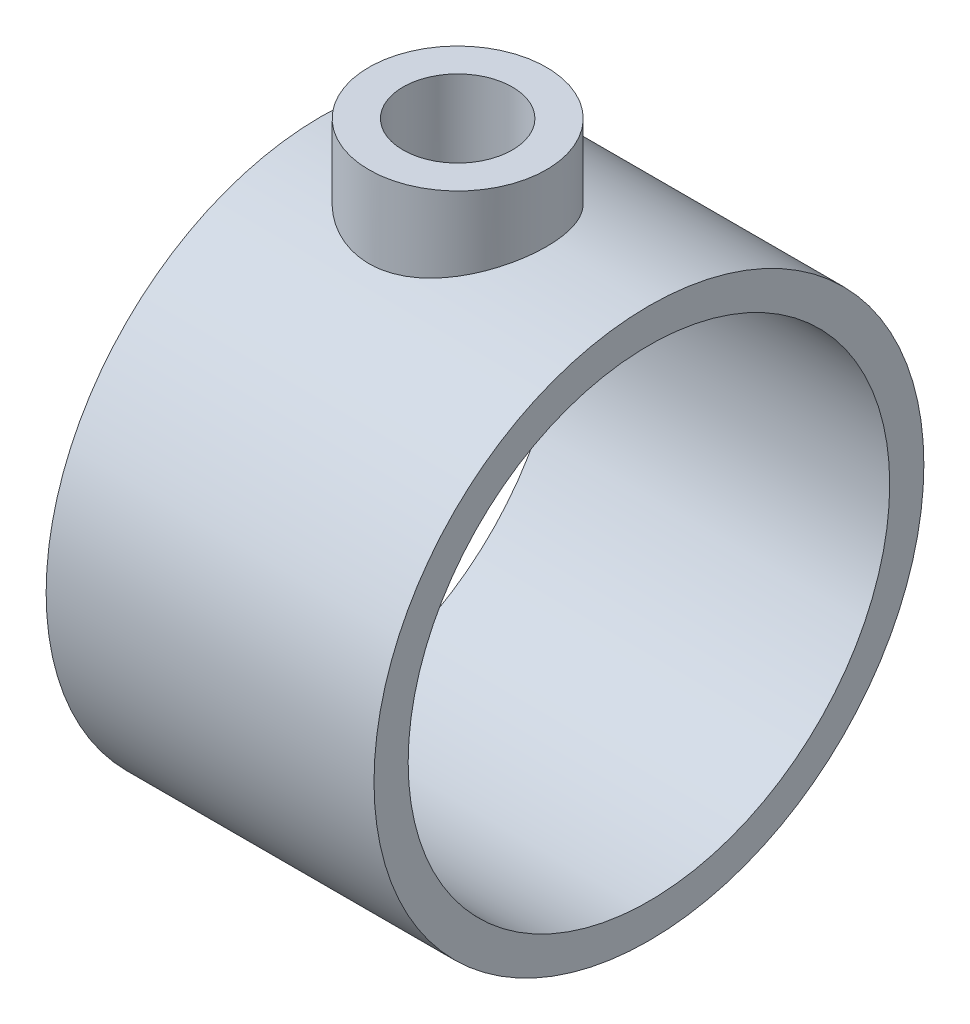
from build123d import *

# Parameters (mm, degrees)
SKETCH_10_R         = 1.3
EXTRUDE_1_DEPTH     = 1.3
SKETCH_11_R         = 0.8
CUT_EXTRUDE_2_DEPTH = 5.65


with BuildPart() as part:
    # 草图1 → 旋转1 (revolve)
    with BuildSketch(Plane.XY):
        Polygon((3.380941288, 3.525), (4.357609697, 3.525), (4.769072518, 3.525), (8.180941288, 3.525), (8.180941288, 4.025), (7.380941288, 4.025), (3.380941288, 4.025), align=None)
    revolve(axis=Axis((0, 0, 0), (1, 0, 0)))

    # 草图10 → 凸台-拉伸1 (add)
    with BuildSketch(Plane(origin=(0, 5, 0), x_dir=(1, 0, 0), z_dir=(0, 1, 0))):
        with Locations((5.380941288, 0)):
            Circle(SKETCH_10_R)
    extrude(amount=-EXTRUDE_1_DEPTH)

    # 草图11 → 切除-拉伸2 (cut, symmetric)
    with BuildSketch(Plane(origin=(0, 5, 0), x_dir=(1, 0, 0), z_dir=(0, 1, 0))):
        with Locations((5.380941288, 0)):
            Circle(SKETCH_11_R)
    extrude(amount=CUT_EXTRUDE_2_DEPTH, both=True, mode=Mode.SUBTRACT)


solid = part.part
